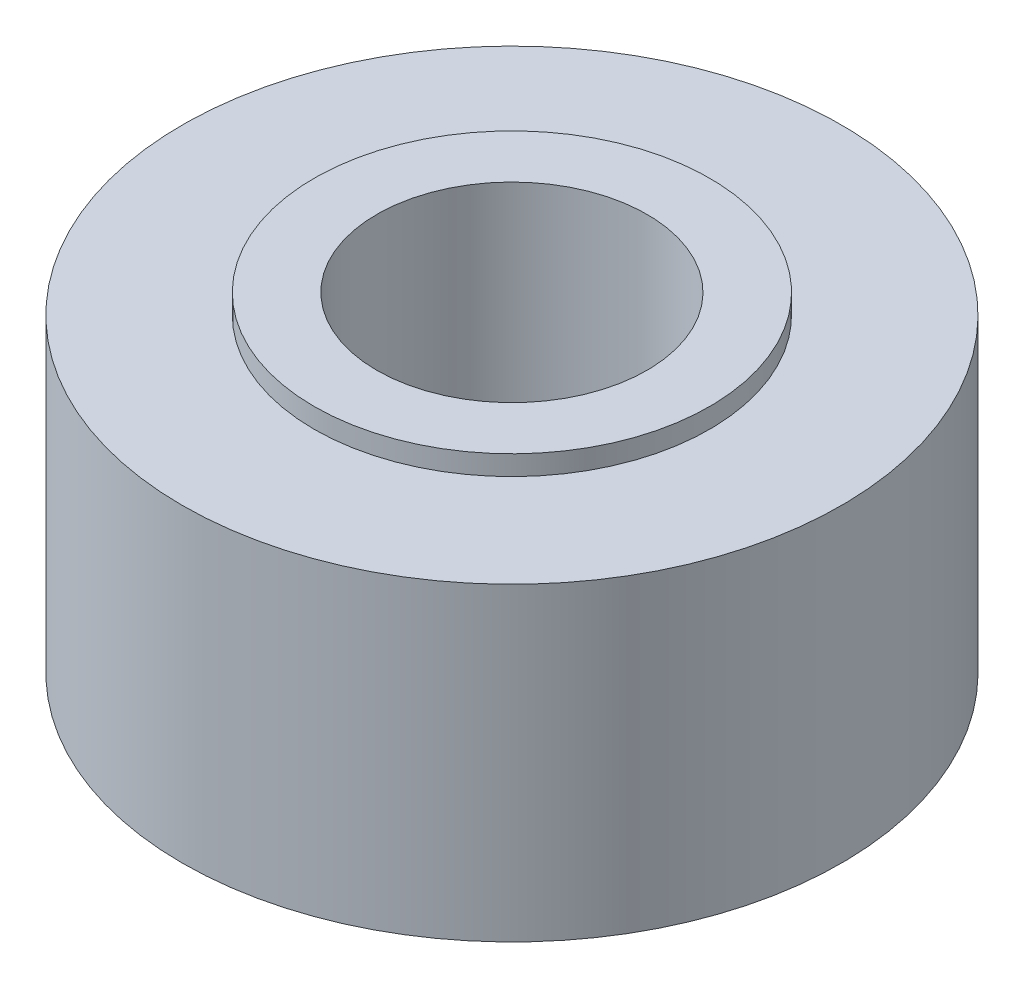
from build123d import *

# Parameters (mm, degrees)
SKETCH_1_R          = 5
EXTRUDE_1_DEPTH     = 4.7
SKETCH_2_R          = 3
EXTRUDE_2_DEPTH     = 0.3
SKETCH_3_R          = 2.05
CUT_EXTRUDE_1_DEPTH = 6


with BuildPart() as part:
    # 스케치1 → 보스-돌출1 (new body)
    with BuildSketch(Plane(origin=(0, 0, 0), x_dir=(1, 0, 0), z_dir=(0, 1, 0))):
        Circle(SKETCH_1_R)
    extrude(amount=EXTRUDE_1_DEPTH)

    # 스케치2 → 보스-돌출2 (add)
    with BuildSketch(Plane(origin=(0, 4.7, 0), x_dir=(1, 0, 0), z_dir=(0, 1, 0))):
        Circle(SKETCH_2_R)
    extrude(amount=EXTRUDE_2_DEPTH)

    # 스케치3 → 컷-돌출1 (cut, through all)
    with BuildSketch(Plane(origin=(0, 5, 0), x_dir=(1, 0, 0), z_dir=(0, 1, 0))):
        Circle(SKETCH_3_R)
    extrude(amount=-CUT_EXTRUDE_1_DEPTH, mode=Mode.SUBTRACT)


solid = part.part
